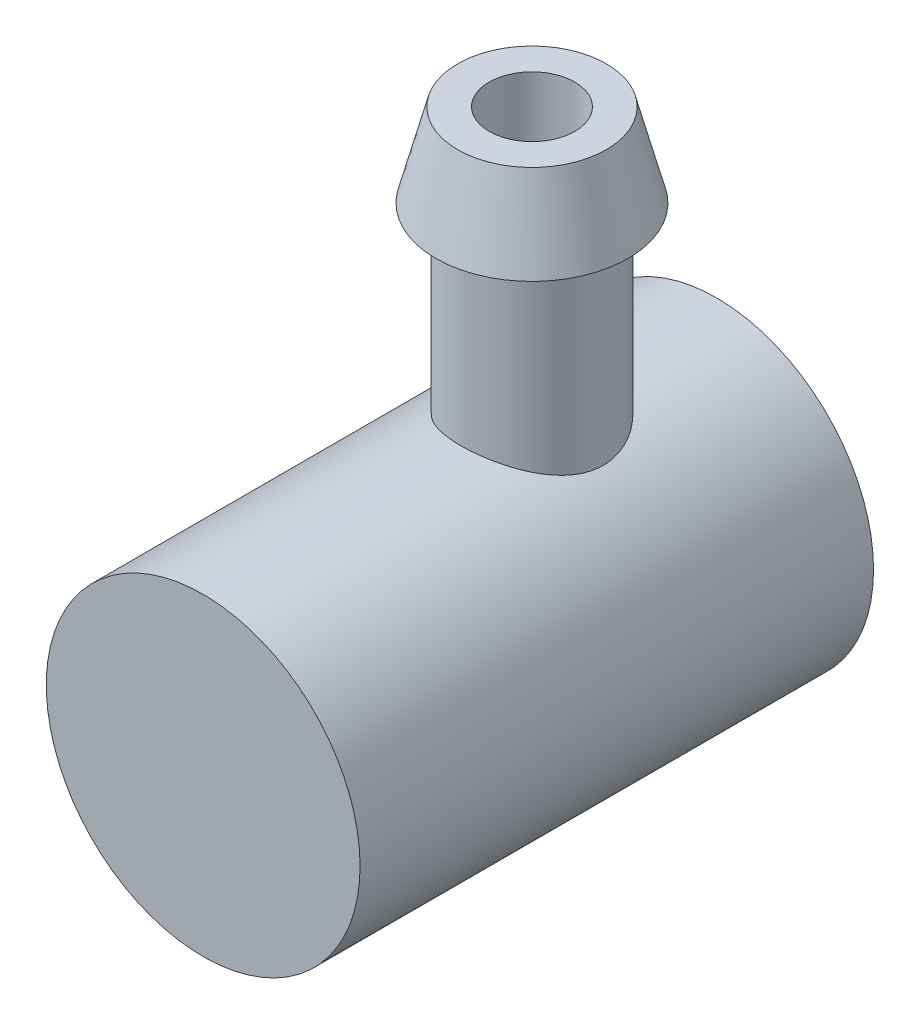
from build123d import *

# Parameters (mm, degrees)
SKETCH1_R           = 5.5
BOSS_EXTRUDE1_DEPTH = 18


with BuildPart() as part:
    # Sketch1 → Boss-Extrude1 (new body)
    with BuildSketch(Plane.XY):
        Circle(SKETCH1_R)
    extrude(amount=-BOSS_EXTRUDE1_DEPTH)

    # Sketch3 → Revolve1 (revolve)
    with BuildSketch(Plane(origin=(0, 0, 0), x_dir=(0, 0, -1), z_dir=(1, 0, 0))):
        Polygon((13.026280971, 14.539629518), (14.13388163, 14.539629518), (14.897758762, 11.619086594), (14.026280971, 11.619086594), (14.026280971, 0.039629518), (13.026280971, 0.039629518), align=None)
    revolve(axis=Axis((0, 14.539629518, -11.526280971), (0, -1, 0)))


solid = part.part
